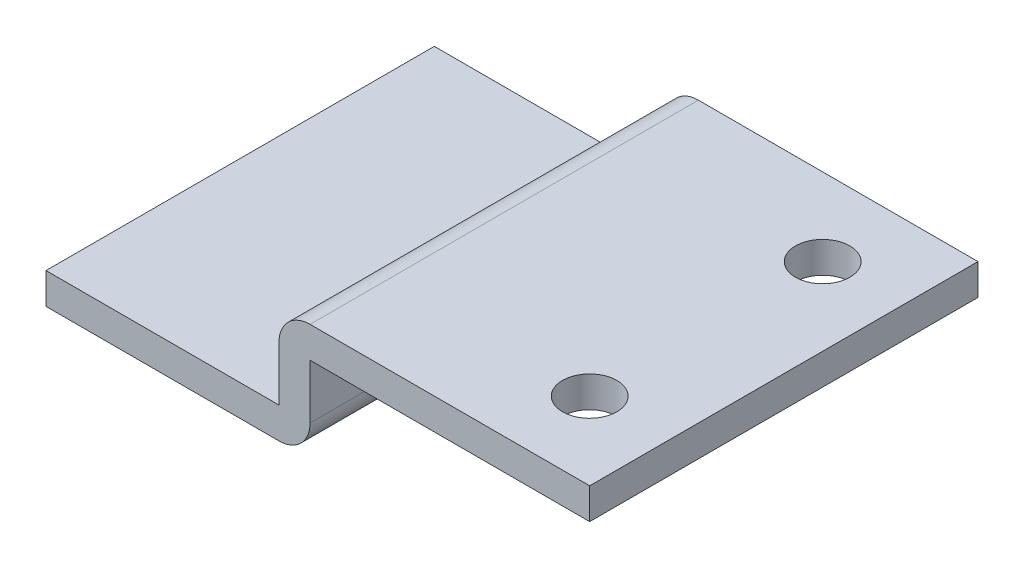
from build123d import *

# Parameters (mm, degrees)
BOSS_EXTRUDE1_DEPTH        = 12.5
FILLET1_R                  = 2
F_3_5_3_5_DIAMETER_HOLE1_D = 3.5


with BuildPart() as part:
    # Sketch1 → Boss-Extrude1 (new body, symmetric)
    with BuildSketch(Plane.XY):
        Polygon((0, 0), (-18, 0), (-18, -5.5), (-35, -5.5), (-35, -3.5), (-20, -3.5), (-20, 2), (0, 2), align=None)
    extrude(amount=BOSS_EXTRUDE1_DEPTH, both=True)

    # Fillet1
    fillet1_edges = [part.edges().sort_by_distance(p)[0] for p in [
        (-18, -5.5, 0),
        (-20, 2, 0),
    ]]
    fillet(fillet1_edges, radius=FILLET1_R)

    # Ø3.5 (3.5) Diameter Hole1 (through all)
    with Locations(Plane(origin=(0, 2, 0), x_dir=(-1, 0, 0), z_dir=(0, 1, 0))):
        with Locations((5, -7.5), (5, 7.5)):
            Hole(F_3_5_3_5_DIAMETER_HOLE1_D / 2)


solid = part.part
